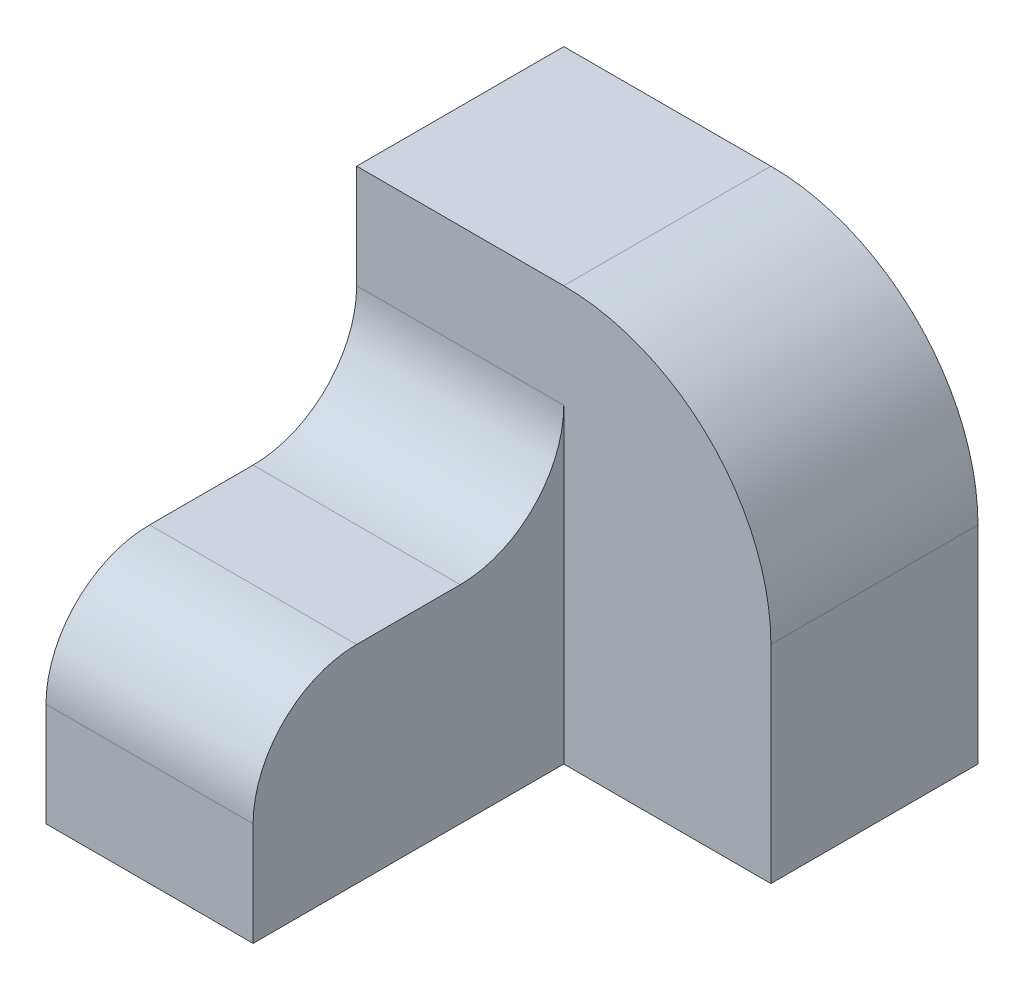
from build123d import *

# Parameters (mm, degrees)
SKETCH_1_W      = 10
SKETCH_1_H      = 15
EXTRUDE_1_DEPTH = 10
EXTRUDE_2_DEPTH = 20
FILLET_1_R      = 5
FILLET_2_R      = 10


with BuildPart() as part:
    # 草圖1 → 填料-伸長1 (new body)
    with BuildSketch(Plane(origin=(0, 0, 0), x_dir=(1, 0, 0), z_dir=(0, 1, 0))):
        with Locations((5, -7.5)):
            Rectangle(SKETCH_1_W, SKETCH_1_H)
    extrude(amount=EXTRUDE_1_DEPTH)

    # 草圖1<3> → 填料-伸長2 (add)
    with BuildSketch(Plane(origin=(0, 0, 0), x_dir=(1, 0, 0), z_dir=(0, 1, 0))):
        Polygon((0, 10), (0, 0), (10, 0), (20, 0), (20, 10), align=None)
    extrude(amount=EXTRUDE_2_DEPTH)

    # 圓角1
    fillet_1_edges = [part.edges().sort_by_distance(p)[0] for p in [
        (5, 10, 0),
        (5, 10, 15),
    ]]
    fillet(fillet_1_edges, radius=FILLET_1_R)

    # 圓角2
    fillet_2_edges = [part.edges().sort_by_distance(p)[0] for p in [
        (20, 20, -5),
    ]]
    fillet(fillet_2_edges, radius=FILLET_2_R)


solid = part.part
